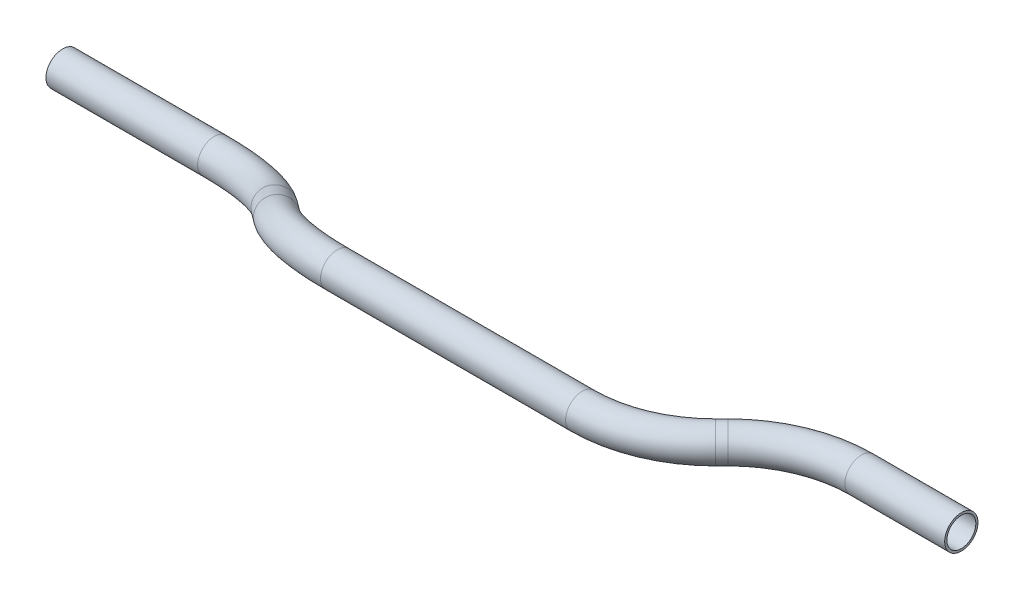
from build123d import *

# Parameters (mm, degrees)
SKETCH1_R   = 9.525
SKETCH1_R_2 = 8.2804


with BuildPart() as part:
    # Sweep2: sweep along a curve in space
    with BuildLine() as sweep2_path:
        Line((0, 0, 0), (86.675584151, 0, 0))
        ThreePointArc((86.675584151, 0, 0), (115.836061697, 2.852226187, 5.050664267), (140.557120878, 10.974679168, 19.433739219))
        Line((140.557120878, 10.974679168, 19.433739219), (151.343858578, 16.278851955, 28.826260781))
        ThreePointArc((151.343858578, 16.278851955, 28.826260781), (176.064917759, 24.401304936, 43.209335733), (205.225395305, 27.253531123, 48.26))
        Line((205.225395305, 27.253531123, 48.26), (345.299248399, 27.253531123, 48.26))
        ThreePointArc((345.299248399, 27.253531123, 48.26), (374.459725945, 27.253531123, 42.459620377), (399.180785126, 27.253531123, 25.941536726))
        Line((399.180785126, 27.253531123, 25.941536726), (402.803858578, 27.253531123, 22.318463274))
        ThreePointArc((402.803858578, 27.253531123, 22.318463274), (427.524917759, 27.253531123, 5.800379623), (456.685395305, 27.253531123, 0))
        Line((456.685395305, 27.253531123, 0), (513.775796056, 27.253531123, 0))
    # Sketch1 → Sweep2 (sweep)
    with BuildSketch(Plane(origin=(0, 0, 0), x_dir=(0, 0, -1), z_dir=(1, 0, 0))):
        Circle(SKETCH1_R)
        Circle(SKETCH1_R_2, mode=Mode.SUBTRACT)
    sweep(path=sweep2_path.line)


solid = part.part
